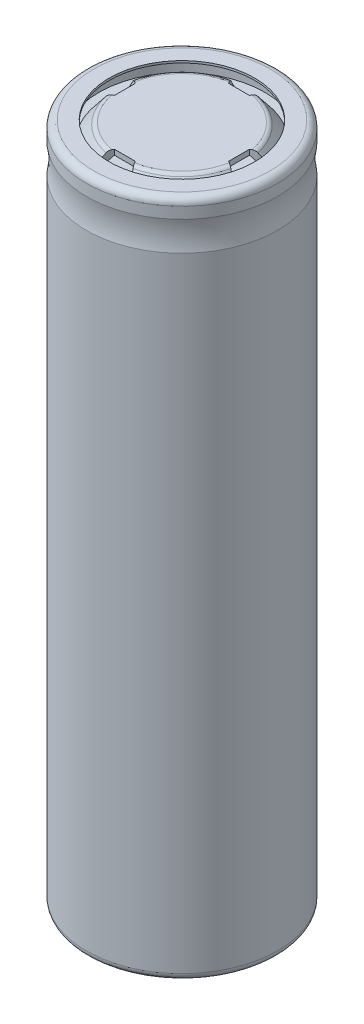
from build123d import *

# Parameters (mm, degrees)
CUT_EXTRUDE_1_DEPTH      = 1
CUT_EXTRUDE_1_DEPTH_BACK = 1.501485988


with BuildPart() as part:
    # Эскиз1 → Повернуть1 (revolve)
    with BuildSketch(Plane.XY):
        with BuildLine():
            Line((0, 0.5), (0, 0))
            Line((0, 0), (8.5, 0))
            ThreePointArc((8.5, 0), (8.853553391, 0.146446609), (9, 0.5))
            Line((9, 0.5), (9, 60.587272326))
            ThreePointArc((9, 60.587272326), (8.90824829, 60.875947461), (8.666666667, 61.058676847))
            ThreePointArc((8.666666667, 61.058676847), (8, 62.001485888), (8.666666667, 62.94429493))
            ThreePointArc((8.666666667, 62.94429493), (8.90824829, 63.127024316), (9, 63.415699451))
            Line((9, 63.415699451), (9, 64.5))
            ThreePointArc((9, 64.5), (8.498514112, 65.001485888), (7.997028223, 64.5))
            Line((7.997028223, 64.5), (7.997028223, 63.5))
            Line((7.997028223, 63.5), (7.2, 63.5))
            Line((7.2, 63.5), (6.150171734, 64.813585272))
            ThreePointArc((6.150171734, 64.813585272), (5.976233912, 64.95205247), (5.759462711, 65.00142632))
            Line((5.759462711, 65.00142632), (0, 65))
            Line((0, 65), (0, 64.5))
            Line((0, 64.5), (5.608751555, 64.5))
            Line((5.608751555, 64.5), (6.7, 63.5))
            Line((6.7, 63.5), (0, 63.5))
            Line((0, 63.5), (0, 63))
            Line((0, 63), (8.2, 63))
            Line((8.2, 63), (8.2, 63.5))
            Line((8.2, 63.5), (8.498514112, 63.5))
            Line((8.498514112, 63.5), (8.498514112, 63.415173231))
            ThreePointArc((8.498514112, 63.415173231), (8.406914027, 63.126712646), (8.165676074, 62.943944117))
            ThreePointArc((8.165676074, 62.943944117), (7.500000138, 62.00096045), (8.166666667, 61.058676847))
            ThreePointArc((8.166666667, 61.058676847), (8.40824829, 60.875947461), (8.5, 60.587272326))
            Line((8.5, 60.587272326), (8.5, 0.5))
            Line((8.5, 0.5), (0, 0.5))
        make_face()
    revolve(axis=Axis((0, 0, 0), (0, 1, 0)))

    # Эскиз2 → Вырез-Вытянуть1 (cut, two sides)
    with BuildSketch(Plane.XZ.offset(-64.5)) as cut_extrude_1_sk:
        Polygon((-1, -5.495703298), (1, -5.495703298), (2, -7.2), (-2, -7.2), align=None)
        Polygon((-5.495703298, 1), (-5.495703298, -1), (-7.2, -2), (-7.2, 2), align=None)
        Polygon((1, 5.495703298), (-1, 5.495703298), (-2, 7.2), (2, 7.2), align=None)
        Polygon((5.495703298, -1), (5.495703298, 1), (7.2, 2), (7.2, -2), align=None)
    extrude(amount=CUT_EXTRUDE_1_DEPTH, mode=Mode.SUBTRACT)
    extrude(cut_extrude_1_sk.sketch, amount=-CUT_EXTRUDE_1_DEPTH_BACK, mode=Mode.SUBTRACT)


with BuildPart() as body_2:
    # Эскиз3 → Повернуть4 (revolve)
    with BuildSketch(Plane.XY):
        with BuildLine():
            Line((8.497664073, 0), (7, 0))
            Line((7, 0), (7, -0.2))
            Line((7, -0.2), (8.5, -0.2))
            ThreePointArc((8.5, -0.2), (8.994974747, 0.005025253), (9.2, 0.5))
            Line((9.2, 0.5), (9.2, 60.587272326))
            add(Edge.make_bspline(
                [(9.2, 63.416313782), (8.901392965, 61.953947415), (9.2, 60.587272326)],
                knots=[0, 0, 0, 0.679954534, 0.679954534, 0.679954534], degree=2))
            Line((9.2, 63.416313782), (9.2, 64.5))
            ThreePointArc((9.2, 64.5), (8.99453954, 64.996025429), (8.498514112, 65.201485888))
            Line((8.498514112, 65.201485888), (7, 65.201485888))
            Line((7, 65.201485888), (7, 65.001485888))
            Line((7, 65.001485888), (8.496178619, 65.00148045))
            ThreePointArc((8.496178619, 65.00148045), (8.852291499, 64.855428835), (9, 64.5))
            Line((9, 64.5), (9, 63.415699451))
            add(Edge.make_bspline(
                [(9, 63.415699451), (8.697080045, 61.944299731), (9, 60.587272326)],
                knots=[0, 0, 0, 0.587527579, 0.587527579, 0.587527579], degree=2))
            Line((9, 60.587272326), (9, 0.5))
            ThreePointArc((9, 0.5), (8.885768464, 0.18190773), (8.595269231, 0.009160135))
            Line((8.595269231, 0.009160135), (8.497664073, 0))
        make_face()
    revolve(axis=Axis((0, -2.74002086, 0), (0, 1, 0)))


solid = Compound([part.part, body_2.part])
